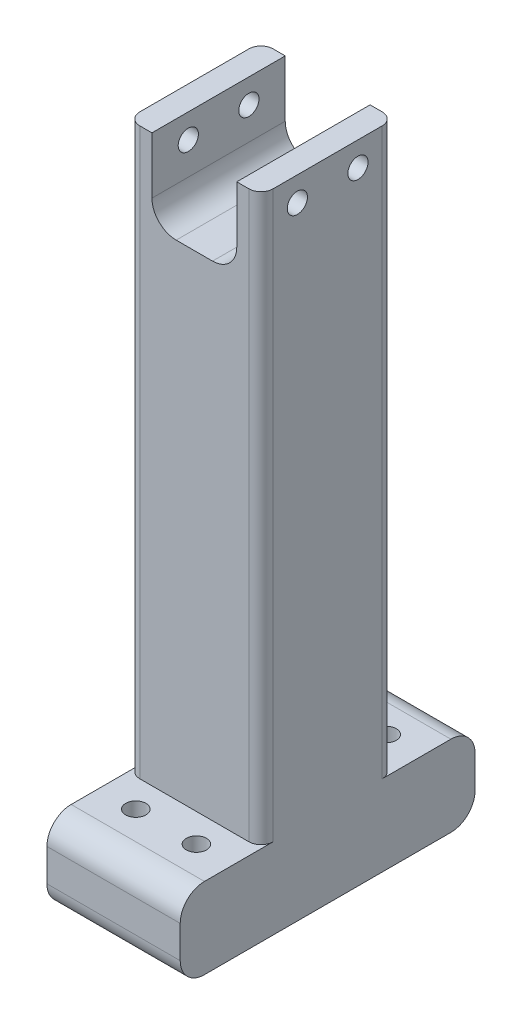
from build123d import *

# Parameters (mm, degrees)
SKETCH1_W           = 26.67
SKETCH1_H           = 26.67
BOSS_EXTRUDE1_DEPTH = 5.08
SKETCH9_W           = 41.91
SKETCH9_H           = 41.91
BOSS_EXTRUDE7_DEPTH = 203.2
CUT_EXTRUDE4_DEPTH  = 42.91
SKETCH11_R          = 3.175
CUT_EXTRUDE5_DEPTH  = 42.91
SKETCH12_W          = 41.91
SKETCH12_H          = 25.4
BOSS_EXTRUDE8_DEPTH = 25.4
SKETCH13_R          = 3.175
CUT_EXTRUDE6_DEPTH  = 26.4
FILLET2_R           = 3.81
FILLET3_R           = 7.62


with BuildPart() as part:
    # Sketch1 → Boss-Extrude1 (new body)
    with BuildSketch(Plane(origin=(0, 0, 0), x_dir=(1, 0, 0), z_dir=(0, 1, 0))):
        Rectangle(SKETCH1_W, SKETCH1_H)
    extrude(amount=BOSS_EXTRUDE1_DEPTH)

    # Sketch9 → Boss-Extrude7 (add)
    with BuildSketch(Plane.XZ):
        Rectangle(SKETCH9_W, SKETCH9_H)
    extrude(amount=-BOSS_EXTRUDE7_DEPTH)

    # Sketch10 → Cut-Extrude4 (cut, through all)
    with BuildSketch(Plane.XY.offset(20.955)):
        with BuildLine():
            Line((-13.335, 185.42), (-13.335, 203.2))
            Line((-13.335, 203.2), (13.335, 203.2))
            Line((13.335, 203.2), (13.335, 185.42))
            ThreePointArc((13.335, 185.42), (11.103153673, 180.031846327), (5.715, 177.8))
            Line((5.715, 177.8), (-5.715, 177.8))
            ThreePointArc((-5.715, 177.8), (-11.103153673, 180.031846327), (-13.335, 185.42))
        make_face()
    extrude(amount=-CUT_EXTRUDE4_DEPTH, mode=Mode.SUBTRACT)

    # Sketch11 → Cut-Extrude5 (cut, through all)
    with BuildSketch(Plane.ZY.offset(20.955)):
        with Locations((-9.525, 195.58)):
            Circle(SKETCH11_R)
        with Locations((9.525, 195.58)):
            Circle(SKETCH11_R)
    extrude(amount=-CUT_EXTRUDE5_DEPTH, mode=Mode.SUBTRACT)

    # Sketch12 → Boss-Extrude8 (add)
    with BuildSketch(Plane.XY.offset(20.955)):
        with Locations((0, 12.7)):
            Rectangle(SKETCH12_W, SKETCH12_H)
    boss_extrude8 = extrude(amount=BOSS_EXTRUDE8_DEPTH)

    # Sketch13 → Cut-Extrude6 (cut, through all)
    with BuildSketch(Plane(origin=(0, 25.4, 0), x_dir=(1, 0, 0), z_dir=(0, 1, 0))):
        with Locations((-9.525, -29.845)):
            Circle(SKETCH13_R)
        with Locations((9.525, -29.845)):
            Circle(SKETCH13_R)
    cut_extrude6 = extrude(amount=-CUT_EXTRUDE6_DEPTH, mode=Mode.SUBTRACT)

    # Mirror1: Boss-Extrude8, Cut-Extrude6 across plane
    add(boss_extrude8.mirror(Plane.XY))
    add(cut_extrude6.mirror(Plane.XY), mode=Mode.SUBTRACT)

    # Fillet2
    fillet2_edges = [part.edges().sort_by_distance(p)[0] for p in [
        (20.955, 114.3, -20.955),
        (-20.955, 114.3, -20.955),
        (-20.955, 114.3, 20.955),
        (20.955, 114.3, 20.955),
    ]]
    fillet(fillet2_edges, radius=FILLET2_R)

    # Fillet3
    fillet3_edges = [part.edges().sort_by_distance(p)[0] for p in [
        (0, 0, 46.355),
        (0, 25.4, 46.355),
        (0, 25.4, -46.355),
        (0, 0, -46.355),
    ]]
    fillet(fillet3_edges, radius=FILLET3_R)


solid = part.part
